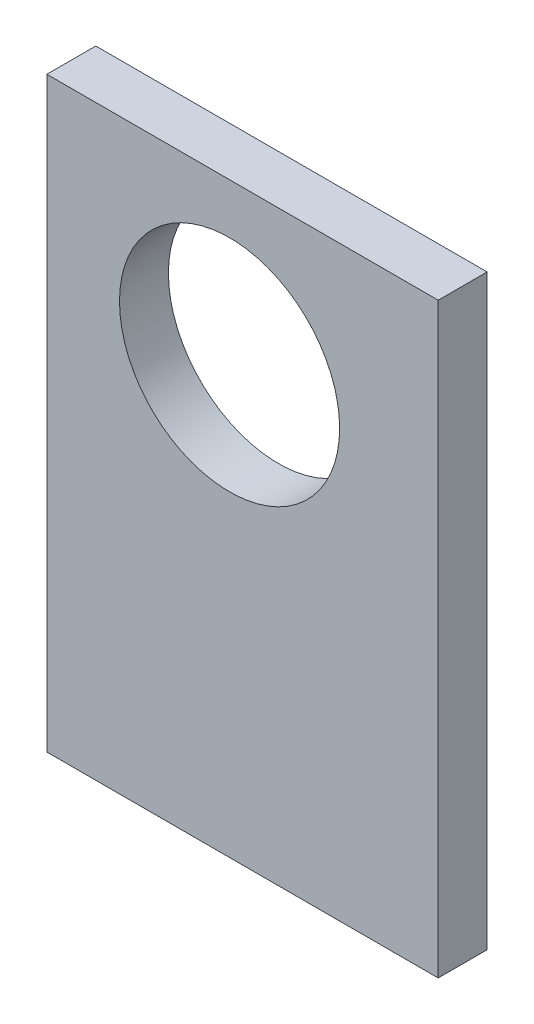
from build123d import *

# Parameters (mm, degrees)
SKETCH1_W           = 50.8
SKETCH1_H           = 76.2
BOSS_EXTRUDE1_DEPTH = 6.35
SKETCH2_R           = 14.2875
CUT_EXTRUDE1_DEPTH  = 6.35


with BuildPart() as part:
    # Sketch1 → Boss-Extrude1 (new body)
    with BuildSketch(Plane.XY):
        with Locations((-25.737541528, 10.505980066)):
            Rectangle(SKETCH1_W, SKETCH1_H)
    extrude(amount=BOSS_EXTRUDE1_DEPTH)

    # Sketch2 → Cut-Extrude1 (cut)
    with BuildSketch(Plane.XY.offset(6.35)):
        with Locations((-27.421786529, 27.802600454)):
            Circle(SKETCH2_R)
    extrude(amount=-CUT_EXTRUDE1_DEPTH, mode=Mode.SUBTRACT)


solid = part.part
